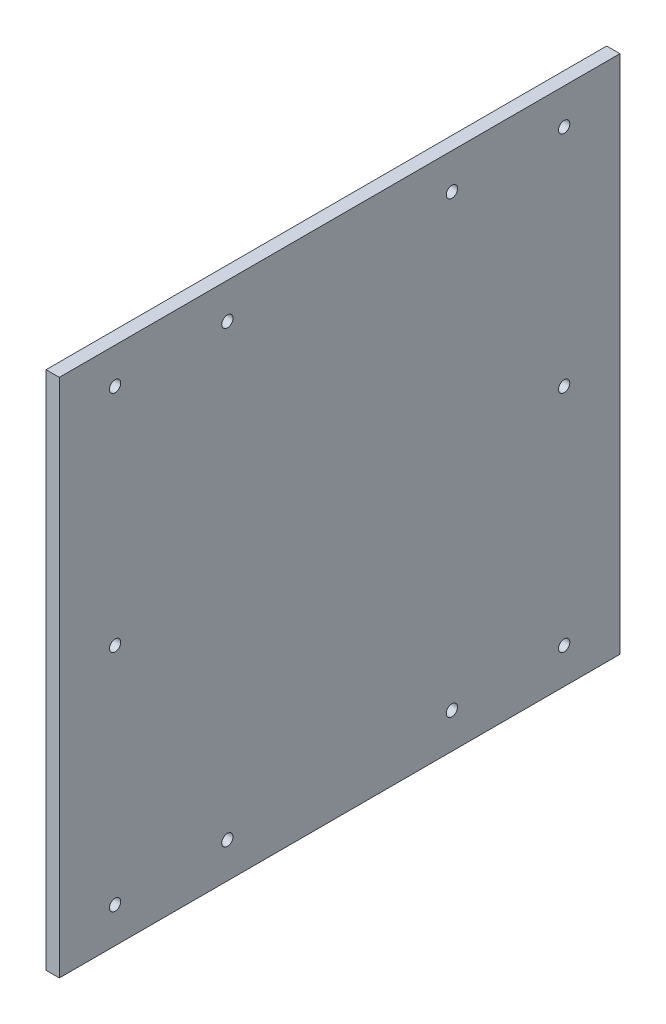
from build123d import *

# Parameters (mm, degrees)
SKETCH1_W           = 235.4
SKETCH1_H           = 253.7
BOSS_EXTRUDE1_DEPTH = 6
SKETCH1_3_R         = 2.555
CUT_EXTRUDE1_DEPTH  = 10


with BuildPart() as part:
    # Sketch1 → Boss-Extrude1 (new body)
    with BuildSketch(Plane.YZ):
        Rectangle(SKETCH1_W, SKETCH1_H)
    extrude(amount=BOSS_EXTRUDE1_DEPTH)

    # Sketch1_3 → Cut-Extrude1 (cut)
    with BuildSketch(Plane.YZ):
        with Locations((-101.6, 101.6)):
            Circle(SKETCH1_3_R)
        with Locations((101.6, 101.6)):
            Circle(SKETCH1_3_R)
        with Locations((-101.6, -101.6)):
            Circle(SKETCH1_3_R)
        with Locations((101.6, -101.6)):
            Circle(SKETCH1_3_R)
        with Locations((0, -101.6)):
            Circle(SKETCH1_3_R)
        with Locations((0, 101.6)):
            Circle(SKETCH1_3_R)
        with Locations((-101.6, -50.8)):
            Circle(SKETCH1_3_R)
        with Locations((101.6, -50.8)):
            Circle(SKETCH1_3_R)
        with Locations((101.6, 50.8)):
            Circle(SKETCH1_3_R)
        with Locations((-101.6, 50.8)):
            Circle(SKETCH1_3_R)
    extrude(amount=CUT_EXTRUDE1_DEPTH, mode=Mode.SUBTRACT)


solid = part.part
